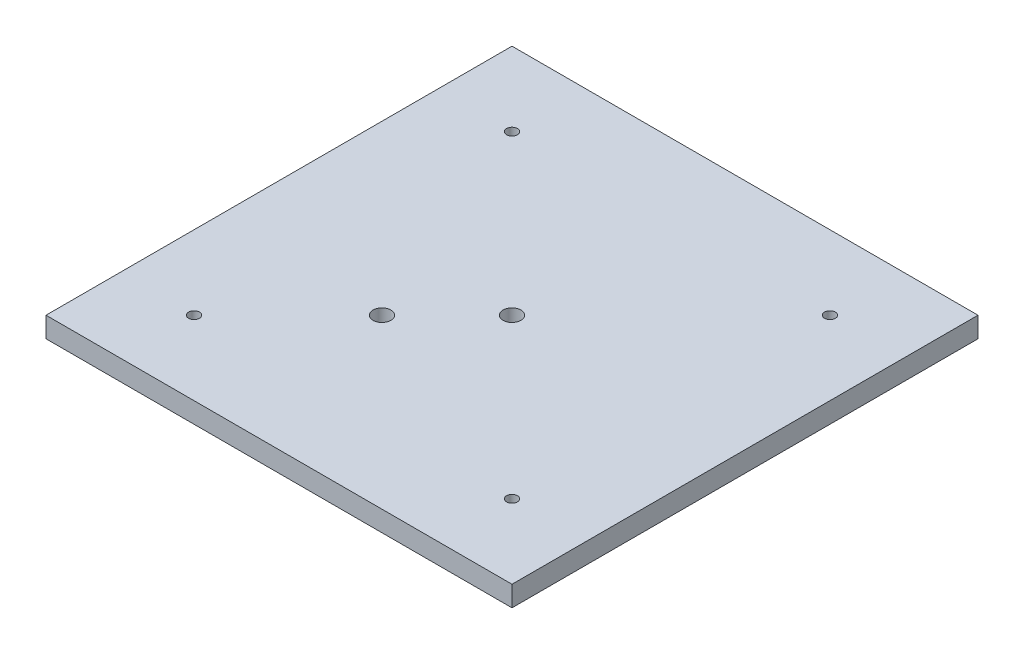
from build123d import *

# Parameters (mm, degrees)
SKETCH1_W                     = 289.56
SKETCH1_H                     = 289.56
BOSS_EXTRUDE1_DEPTH           = 12.7
PIPE_TAP_DRILL_FOR_1_4_TAP2_D = 11.1252
PIPE_TAP_DRILL_FOR_1_4_TAP1_D = 11.1252
F_1_4_CLEARANCE_HOLE1_D       = 6.7564
SKETCH12_R                    = 127.635
SKETCH12_R_2                  = 123.19
CUT_EXTRUDE1_DEPTH            = 9.525
CIRPATTERN1_COUNT             = 4


with BuildPart() as part:
    # Sketch1 → Boss-Extrude1 (new body)
    with BuildSketch(Plane(origin=(0, 0, 0), x_dir=(1, 0, 0), z_dir=(0, 1, 0))):
        Rectangle(SKETCH1_W, SKETCH1_H)
    extrude(amount=BOSS_EXTRUDE1_DEPTH)

    # Pipe Tap Drill for 1/4 Tap2 (through all)
    with Locations(Plane(origin=(0, 12.7, 0), x_dir=(1, 0, 0), z_dir=(0, 1, 0))):
        with Locations((0, 0)):
            Hole(PIPE_TAP_DRILL_FOR_1_4_TAP2_D / 2)

    # Pipe Tap Drill for 1/4 Tap1 (through all)
    with Locations(Plane(origin=(0, 12.7, 0), x_dir=(1, 0, 0), z_dir=(0, 1, 0))):
        with Locations((-40.411152545, -40.411152545)):
            Hole(PIPE_TAP_DRILL_FOR_1_4_TAP1_D / 2)

    # 1/4 Clearance Hole1 (through all)
    with Locations(Plane(origin=(0, 12.7, 0), x_dir=(1, 0, 0), z_dir=(0, 1, 0))):
        with Locations((-98.782817332, -98.782817332)):
            f_1_4_clearance_hole1 = Hole(F_1_4_CLEARANCE_HOLE1_D / 2)

    # Sketch12 → Cut-Extrude1 (cut)
    with BuildSketch(Plane.XZ):
        Circle(SKETCH12_R)
        Circle(SKETCH12_R_2, mode=Mode.SUBTRACT)
    extrude(amount=-CUT_EXTRUDE1_DEPTH, mode=Mode.SUBTRACT)

    # CirPattern1: 1/4 Clearance Hole1 ×4 about axis
    cirpattern1_axis = Axis((0, 0, 0), (0, 1, 0))
    for i in range(1, CIRPATTERN1_COUNT):
        add(f_1_4_clearance_hole1.rotate(cirpattern1_axis, i * 360 / CIRPATTERN1_COUNT), mode=Mode.SUBTRACT)


solid = part.part
